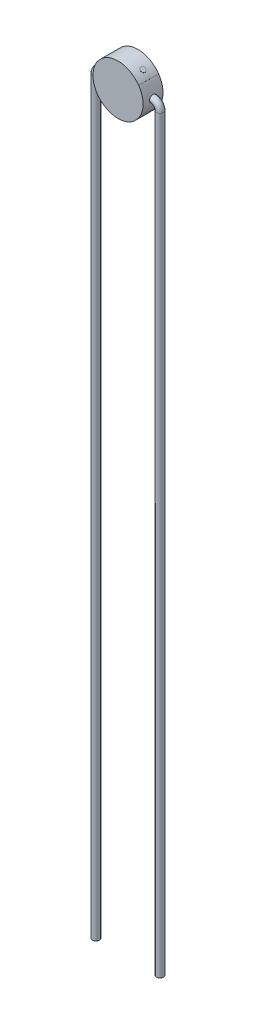
from build123d import *

# Parameters (mm, degrees)
SKETCH1_R           = 2.5
BOSS_EXTRUDE3_DEPTH = 1
BOSS_EXTRUDE4_DEPTH = 2
SKETCH12_4_R        = 0.25
BOSS_EXTRUDE5_DEPTH = 0.01
SWEEP20_PROFILE_R   = 0.35
SWEEP21_PROFILE_R   = 0.35


with BuildPart() as part:
    # Sketch1 → Boss-Extrude3 (new body, symmetric)
    with BuildSketch(Plane.XY):
        Circle(SKETCH1_R)
    extrude(amount=BOSS_EXTRUDE3_DEPTH, both=True)

    # Sketch2 → Boss-Extrude4 (add)
    with BuildSketch(Plane.XY.offset(1)):
        with BuildLine():
            Line((2.063339037, 1.411606183), (2.071592393, 1.417252608))
            ThreePointArc((2.071592393, 1.417252608), (2.51, 0), (2.071592393, -1.417252608))
            Line((2.071592393, -1.417252608), (2.063339037, -1.411606183))
            ThreePointArc((2.063339037, -1.411606183), (2.5, 0), (2.063339037, 1.411606183))
        make_face()
    boss_extrude4 = extrude(amount=-BOSS_EXTRUDE4_DEPTH)

    # Mirror1: Boss-Extrude4 across plane
    add(boss_extrude4.mirror(Plane(origin=(0, 0, 0), x_dir=(0, 0, 1), z_dir=(1, 0, 0))))


with BuildPart() as body_2:
    # Sketch12_4 → Boss-Extrude5 (new body)
    with BuildSketch(Plane(origin=(1.5, 2, 0), x_dir=(0.8, -0.6, 0), z_dir=(0.6, 0.8, 0))):
        with Locations(Location((0, 0, 0), (0, 0, 180))):  # turned: the seam where the file's is
            Circle(SKETCH12_4_R)
    extrude(amount=BOSS_EXTRUDE5_DEPTH)


with BuildPart() as body_3:
    # Sweep20: sweep along a path in Sketch14
    with BuildLine(Plane.XY) as sweep20_path:
        Line((3.21, -75.7), (3.21, -0.7))
        ThreePointArc((3.21, -0.7), (3.004974747, -0.205025253), (2.51, 0))
    # Sweep20 profile (on start of the path) → Sweep20 (sweep)
    with BuildSketch(Plane(origin=(3.21, -75.7, 0), x_dir=(1, 0, 0), z_dir=(0, 1, 0))):
        Circle(SWEEP20_PROFILE_R)
    sweep(path=sweep20_path.line)


with BuildPart() as body_4:
    # Sweep21: sweep along a path in Sketch157
    with BuildLine(Plane(origin=(0, 0, 0), x_dir=(-1, 0, 0), z_dir=(0, 0, -1))) as sweep21_path:
        Line((3.21, -75.7), (3.21, -0.7))
        ThreePointArc((3.21, -0.7), (3.004974747, -0.205025253), (2.51, 0))
    # Sweep21 profile (on start of the path) → Sweep21 (sweep)
    with BuildSketch(Plane(origin=(-3.21, -75.7, 0), x_dir=(1, 0, 0), z_dir=(0, 1, 0))):
        Circle(SWEEP21_PROFILE_R)
    sweep(path=sweep21_path.line)


solid = Compound([part.part, body_2.part, body_3.part, body_4.part])
